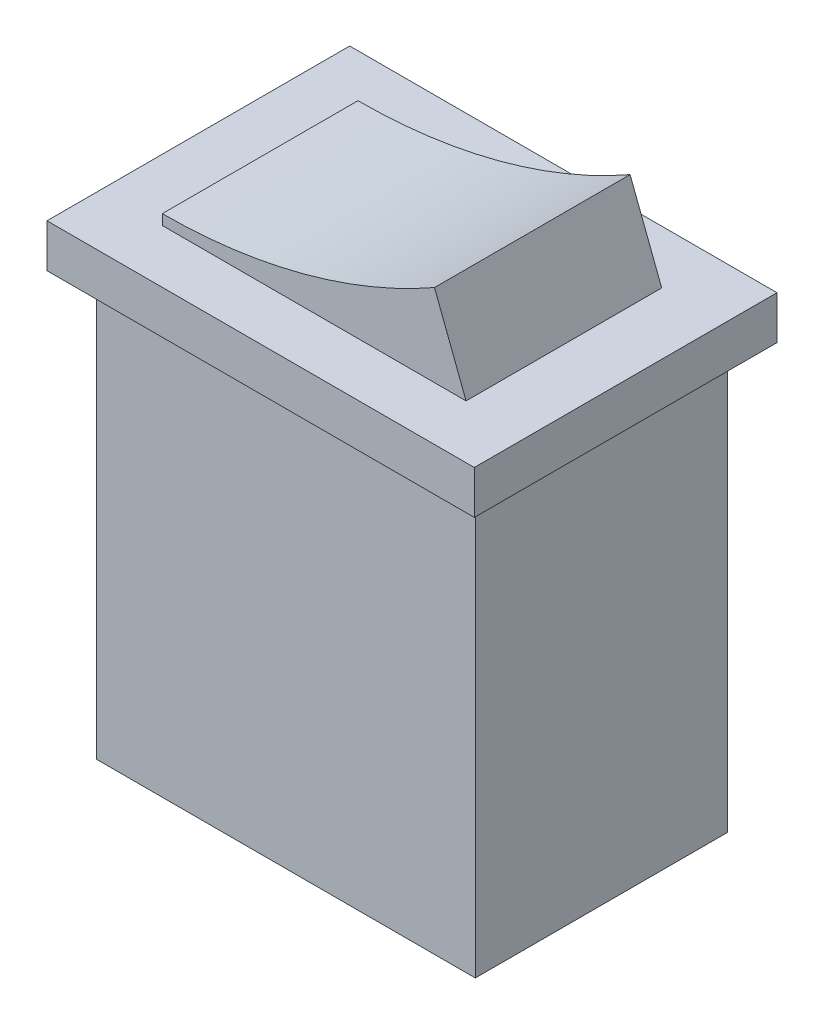
from build123d import *

# Parameters (mm, degrees)
BOSS_EXTRUDE1_DEPTH      = 6.125
BOSS_EXTRUDE1_DEPTH_BACK = 6.125
SKETCH1_W                = 18.4
SKETCH1_H                = 20.57
BOSS_EXTRUDE2_DEPTH      = 7.35
BOSS_EXTRUDE2_DEPTH_BACK = 7.35
BOSS_EXTRUDE3_DEPTH      = 4.75
BOSS_EXTRUDE3_DEPTH_BACK = 4.75


with BuildPart() as part:
    # Sketch1 → Boss-Extrude1 (new, two sides: drawn at the far end of the back side and taken through both)
    with BuildSketch(Plane.XY.offset(-BOSS_EXTRUDE1_DEPTH_BACK)):
        Rectangle(SKETCH1_W, SKETCH1_H)
    extrude(amount=BOSS_EXTRUDE1_DEPTH + BOSS_EXTRUDE1_DEPTH_BACK)

    # Sketch1_3 → Boss-Extrude2 (add, two sides: drawn at the far end of the back side and taken through both)
    with BuildSketch(Plane.XY.offset(-BOSS_EXTRUDE2_DEPTH_BACK)):
        Polygon((7.375, 12.385), (-7.375, 12.385), (-10.375, 12.385), (-10.375, 10.285), (-9.2, 10.285), (9.2, 10.285), (10.375, 10.285), (10.375, 12.385), align=None)
    extrude(amount=BOSS_EXTRUDE2_DEPTH + BOSS_EXTRUDE2_DEPTH_BACK)

    # Sketch1_4 → Boss-Extrude3 (add, two sides: drawn at the far end of the back side and taken through both)
    with BuildSketch(Plane.XY.offset(-BOSS_EXTRUDE3_DEPTH_BACK)):
        with BuildLine():
            Line((-7.375, 12.885), (-7.375, 12.385))
            Line((-7.375, 12.385), (7.375, 12.385))
            Line((7.375, 12.385), (5.840957819, 16.385))
            ThreePointArc((5.840957819, 16.385), (-0.539220215, 13.77482664), (-7.375, 12.885))
        make_face()
    extrude(amount=BOSS_EXTRUDE3_DEPTH + BOSS_EXTRUDE3_DEPTH_BACK)


solid = part.part
